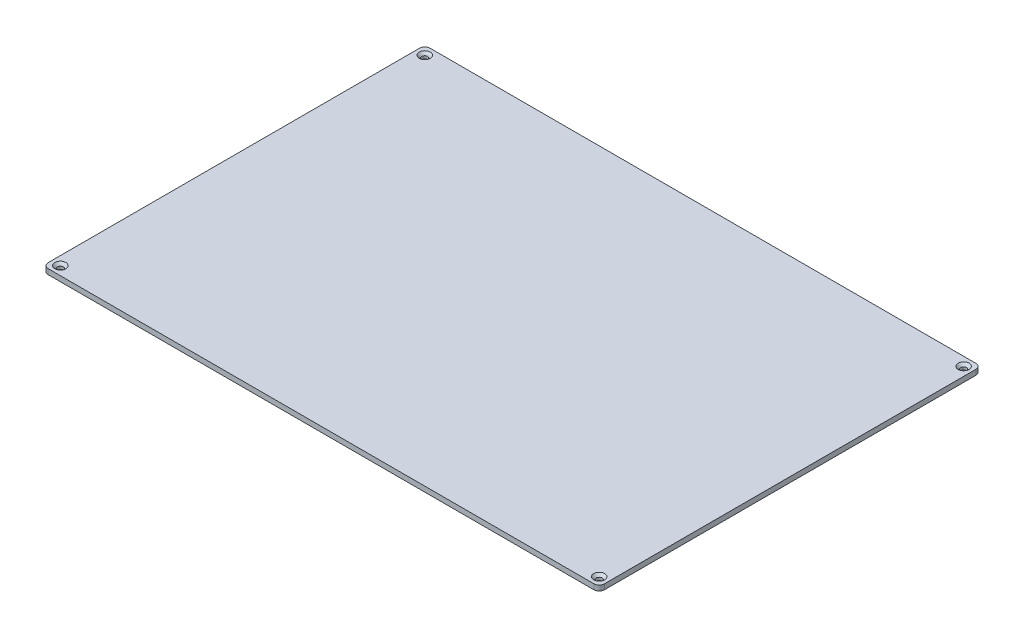
from build123d import *

# Parameters (mm, degrees)
BOSS_EXTRUDE1_DEPTH                            = 3
CSK_FOR_M3_FLAT_HEAD_MACHINE_SCREW1_AT_2_COUNT = 2
CSK_FOR_M3_FLAT_HEAD_MACHINE_SCREW1_AT_2_PITCH = 209
CSK_FOR_M3_FLAT_HEAD_MACHINE_SCREW1_AT_3_COUNT = 2
CSK_FOR_M3_FLAT_HEAD_MACHINE_SCREW1_AT_3_PITCH = 373.044233302
CSK_FOR_M3_FLAT_HEAD_MACHINE_SCREW1_AT_4_COUNT = 2
CSK_FOR_M3_FLAT_HEAD_MACHINE_SCREW1_AT_4_PITCH = 309


with BuildPart() as part:
    # Sketch1 → Boss-Extrude1 (new body)
    with BuildSketch(Plane(origin=(0, 0, 0), x_dir=(1, 0, 0), z_dir=(0, 1, 0))):
        with BuildLine():
            Line((-156.5, 109.5), (156.5, 109.5))
            ThreePointArc((156.5, 109.5), (158.621320344, 108.621320344), (159.5, 106.5))
            Line((159.5, 106.5), (159.5, -106.5))
            ThreePointArc((159.5, -106.5), (158.621320344, -108.621320344), (156.5, -109.5))
            Line((156.5, -109.5), (-156.5, -109.5))
            ThreePointArc((-156.5, -109.5), (-158.621320344, -108.621320344), (-159.5, -106.5))
            Line((-159.5, -106.5), (-159.5, 106.5))
            ThreePointArc((-159.5, 106.5), (-158.621320344, 108.621320344), (-156.5, 109.5))
        make_face()
    extrude(amount=BOSS_EXTRUDE1_DEPTH)

    # Sketch3 → CSK for M3 Flat Head Machine Screw1 (revolve, cut)
    with BuildSketch(Plane(origin=(-154.5, 3, -104.5), x_dir=(0, 0, 1), z_dir=(1, 0, 0))):
        Polygon((0, 0), (0, 3), (1.7, 3), (1.7, 1.45), (3.15, 0), align=None)
    csk_for_m3_flat_head_machine_screw1 = revolve(axis=Axis((-154.5, 9.35, -104.5), (0, -1, 0)), mode=Mode.SUBTRACT)

    # CSK for M3 Flat Head Machine Screw1 at 2: CSK for M3 Flat Head Machine Screw1 ×2
    with Locations(*[(0, 0, i * CSK_FOR_M3_FLAT_HEAD_MACHINE_SCREW1_AT_2_PITCH) for i in range(1, CSK_FOR_M3_FLAT_HEAD_MACHINE_SCREW1_AT_2_COUNT)]):
        add(csk_for_m3_flat_head_machine_screw1, mode=Mode.SUBTRACT)

    # CSK for M3 Flat Head Machine Screw1 at 3: CSK for M3 Flat Head Machine Screw1 ×2
    with Locations(*[Vector(0.828320002, 0, 0.560255276) * (i * CSK_FOR_M3_FLAT_HEAD_MACHINE_SCREW1_AT_3_PITCH) for i in range(1, CSK_FOR_M3_FLAT_HEAD_MACHINE_SCREW1_AT_3_COUNT)]):
        add(csk_for_m3_flat_head_machine_screw1, mode=Mode.SUBTRACT)

    # CSK for M3 Flat Head Machine Screw1 at 4: CSK for M3 Flat Head Machine Screw1 ×2
    with Locations(*[(i * CSK_FOR_M3_FLAT_HEAD_MACHINE_SCREW1_AT_4_PITCH, 0, 0) for i in range(1, CSK_FOR_M3_FLAT_HEAD_MACHINE_SCREW1_AT_4_COUNT)]):
        add(csk_for_m3_flat_head_machine_screw1, mode=Mode.SUBTRACT)


solid = part.part
